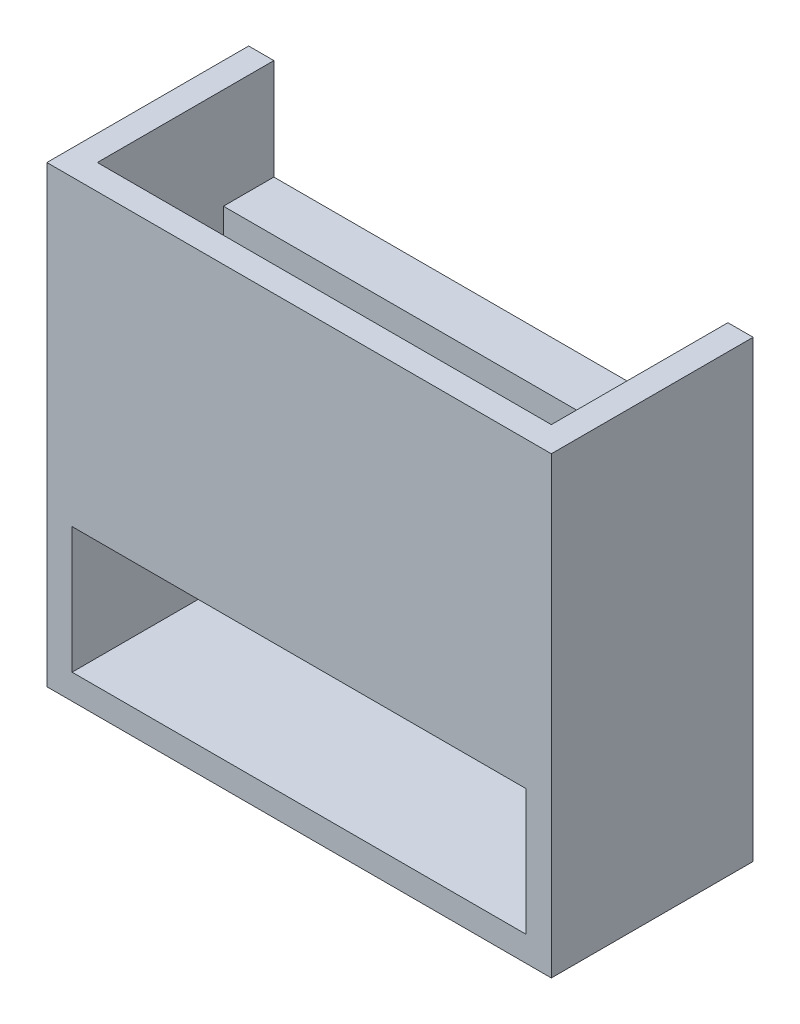
from build123d import *

# Parameters (mm, degrees)
SKETCH1_W           = 20
SKETCH1_H           = 18
BOSS_EXTRUDE1_DEPTH = 8
SKETCH2_W           = 18
SKETCH2_H           = 5
CUT_EXTRUDE1_DEPTH  = 6
SKETCH4_W           = 18
SKETCH4_H           = 5
CUT_EXTRUDE2_DEPTH  = 13
SKETCH5_W           = 18
SKETCH5_H           = 4
CUT_EXTRUDE3_DEPTH  = 4


with BuildPart() as part:
    # Sketch1 → Boss-Extrude1 (new body)
    with BuildSketch(Plane.XY):
        Rectangle(SKETCH1_W, SKETCH1_H)
    extrude(amount=BOSS_EXTRUDE1_DEPTH)

    # Sketch2 → Cut-Extrude1 (cut)
    with BuildSketch(Plane.XY.offset(8)):
        with Locations((0, -5.5)):
            Rectangle(SKETCH2_W, SKETCH2_H)
    extrude(amount=-CUT_EXTRUDE1_DEPTH, mode=Mode.SUBTRACT)

    # Sketch4 → Cut-Extrude2 (cut)
    with BuildSketch(Plane.XZ.offset(3)):
        with Locations((0, 4.5)):
            Rectangle(SKETCH4_W, SKETCH4_H)
    extrude(amount=-CUT_EXTRUDE2_DEPTH, mode=Mode.SUBTRACT)

    # Sketch5 → Cut-Extrude3 (cut)
    with BuildSketch(Plane(origin=(0, 0, 0), x_dir=(-1, 0, 0), z_dir=(0, 0, -1))):
        with Locations((0, 7)):
            Rectangle(SKETCH5_W, SKETCH5_H)
    extrude(amount=-CUT_EXTRUDE3_DEPTH, mode=Mode.SUBTRACT)


solid = part.part
